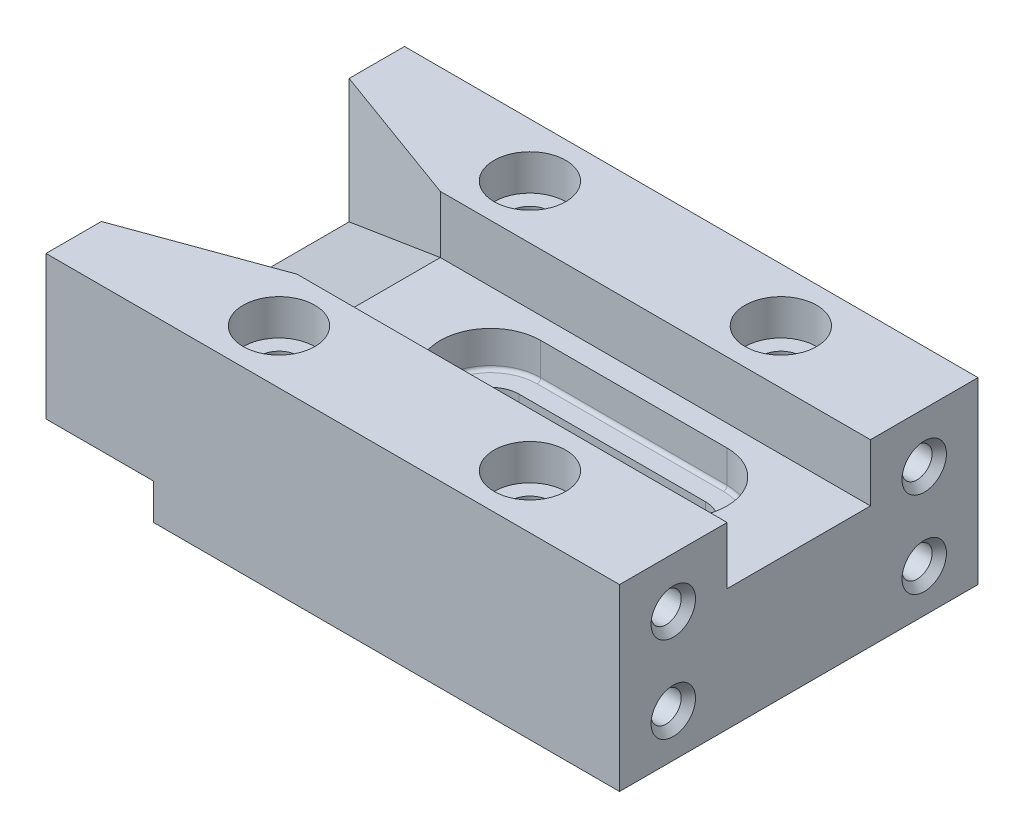
from build123d import *

# Parameters (mm, degrees)
SKICA1_W                 = 80
SKICA1_H                 = 25
P_IDAT_VYSUNUT_M1_DEPTH  = 25
SKICA2_W                 = 15
SKICA2_H                 = 5
ODEBRAT_VYSUNUT_M1_DEPTH = 51
ODEBRAT_VYSUNUT_M2_DEPTH = 8
ZKOSEN_1_SIZE            = 20
ZKOSEN_1_SIZE2           = 9.326153163
ODEBRAT_VYSUNUT_M3_DEPTH = 5
ODEBRAT_VYSUNUT_M4_DEPTH = 13
D_RA1_D                  = 5.5
D_RA1_DEPTH              = 25
D_RA1_CBORE_D            = 10
D_RA1_CBORE_DEPTH        = 5
D_RA1_TIP                = 1.652366702
M5_Z_VIT1_D              = 4.2
M5_Z_VIT1_DEPTH          = 14
M5_Z_VIT1_TIP            = 1.2618073
ZKOSEN_2_SIZE            = 1
ZAOBLIT1_R               = 0.5


with BuildPart() as part:
    # Skica1 → Přidat vysunutím1 (new body, symmetric)
    with BuildSketch(Plane.XY):
        Rectangle(SKICA1_W, SKICA1_H)
    extrude(amount=P_IDAT_VYSUNUT_M1_DEPTH, both=True)

    # Skica2 → Odebrat vysunutím1 (cut, through all)
    with BuildSketch(Plane.XY.offset(25)):
        with Locations((-32.5, -10)):
            Rectangle(SKICA2_W, SKICA2_H)
    extrude(amount=-ODEBRAT_VYSUNUT_M1_DEPTH, mode=Mode.SUBTRACT)

    # Skica3 → Odebrat vysunutím2 (cut)
    with BuildSketch(Plane(origin=(0, 12.5, 0), x_dir=(1, 0, 0), z_dir=(0, 1, 0))):
        Polygon((-40, 17.279404685), (-20, 10), (40, 10), (40, -10), (-20, -10), (-40, -17.279404685), align=None)
    extrude(amount=-ODEBRAT_VYSUNUT_M2_DEPTH, mode=Mode.SUBTRACT)

    # Zkosení1
    zkosen_1_edges = [part.edges().sort_by_distance(p)[0] for p in [
        (-40, 4.5, 0),
    ]]
    zkosen_1_side = [part.faces().sort_by_distance(p)[0] for p in [
        (-2.780115466, 4.5, 0),
    ]]
    chamfer(zkosen_1_edges, length=ZKOSEN_1_SIZE, length2=ZKOSEN_1_SIZE2, reference=zkosen_1_side[0])

    # Skica4 → Odebrat vysunutím3 (cut)
    with BuildSketch(Plane(origin=(0, 4.5, 0), x_dir=(1, 0, 0), z_dir=(0, 1, 0))):
        with BuildLine():
            Line((-3, 7), (23, 7))
            ThreePointArc((23, 7), (30, 0), (23, -7))
            Line((23, -7), (-3, -7))
            ThreePointArc((-3, -7), (-10, 0), (-3, 7))
        make_face()
    extrude(amount=-ODEBRAT_VYSUNUT_M3_DEPTH, mode=Mode.SUBTRACT)

    # Skica5 → Odebrat vysunutím4 (cut, through all)
    with BuildSketch(Plane(origin=(0, -0.5, 0), x_dir=(1, 0, 0), z_dir=(0, 1, 0))):
        with BuildLine():
            Line((-3, -4), (23, -4))
            ThreePointArc((23, -4), (27, 0), (23, 4))
            Line((23, 4), (-3, 4))
            ThreePointArc((-3, 4), (-7, 0), (-3, -4))
        make_face()
    extrude(amount=-ODEBRAT_VYSUNUT_M4_DEPTH, mode=Mode.SUBTRACT)

    # Díra1
    with Locations(Plane(origin=(0, 12.5, 0), x_dir=(1, 0, 0), z_dir=(0, 1, 0))):
        with Locations((-15, 17.5), (20, 17.5), (20, -17.5), (-15, -17.5)):
            CounterBoreHole(D_RA1_D / 2, D_RA1_CBORE_D / 2, D_RA1_CBORE_DEPTH, depth=D_RA1_DEPTH)
            with Locations((0, 0, -(D_RA1_DEPTH + D_RA1_TIP / 2))):  # 118° drill point
                Cone(0, D_RA1_D / 2, D_RA1_TIP, mode=Mode.SUBTRACT)

    # M5 závit1
    with Locations(Plane(origin=(40, 0, 0), x_dir=(0, 0, -1), z_dir=(1, 0, 0))):
        with Locations((-17.5, 5.5), (-17.5, -6.5), (17.5, 5.5), (17.5, -6.5)):
            Hole(M5_Z_VIT1_D / 2, depth=M5_Z_VIT1_DEPTH)
            with Locations((0, 0, -(M5_Z_VIT1_DEPTH + M5_Z_VIT1_TIP / 2))):  # 118° drill point
                Cone(0, M5_Z_VIT1_D / 2, M5_Z_VIT1_TIP, mode=Mode.SUBTRACT)

    # Zkosení2
    zkosen_2_edges = [part.edges().sort_by_distance(p)[0] for p in [
        (40, -6.5, -19.6),
        (40, 5.5, -19.6),
        (40, -6.5, 15.4),
        (40, 5.5, 15.4),
    ]]
    chamfer(zkosen_2_edges, length=ZKOSEN_2_SIZE)

    # Zaoblit1
    zaoblit1_edges = [part.edges().sort_by_distance(p)[0] for p in [
        (-10, -0.5, 0),
        (10, -0.5, -7),
        (30, -0.5, 0),
        (10, -0.5, 7),
    ]]
    fillet(zaoblit1_edges, radius=ZAOBLIT1_R)


solid = part.part
